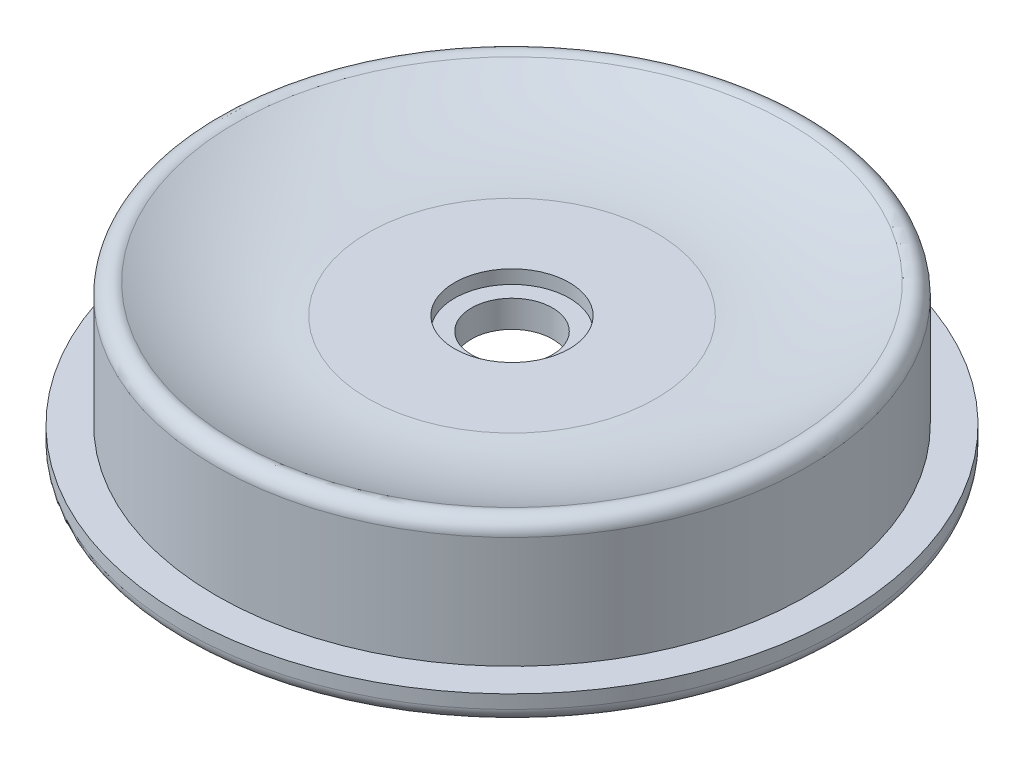
from build123d import *

# Parameters (mm, degrees)
FILLET1_R = 10


with BuildPart() as part:
    # Sketch1 → Revolve1 (revolve)
    with BuildSketch(Plane.XY):
        with BuildLine():
            Line((29, 0), (46.8, 0))
            ThreePointArc((46.8, 0), (48.214213562, 0.585786438), (48.8, 2))
            Line((48.8, 2), (48.8, 4))
            Line((48.8, 4), (43.8, 4))
            Line((43.8, 4), (43.8, 20.522937023))
            ThreePointArc((43.8, 20.522937023), (42.835126597, 22.234226867), (40.871487071, 22.294338655))
            ThreePointArc((40.871487071, 22.294338655), (31.373886886, 18.833953417), (21.3, 18))
            Line((21.3, 18), (8.5, 18))
            Line((8.5, 18), (8.5, 16))
            Line((8.5, 16), (6, 16))
            Line((6, 16), (6, 12))
            Line((6, 12), (29, 12))
            Line((29, 12), (29, 0))
        make_face()
    revolve(axis=Axis((0, 55, 0), (0, -1, 0)))

    # Fillet1
    fillet1_edges = [part.edges().sort_by_distance(p)[0] for p in [
        (-29, 0, 0),
    ]]
    fillet(fillet1_edges, radius=FILLET1_R)


solid = part.part
